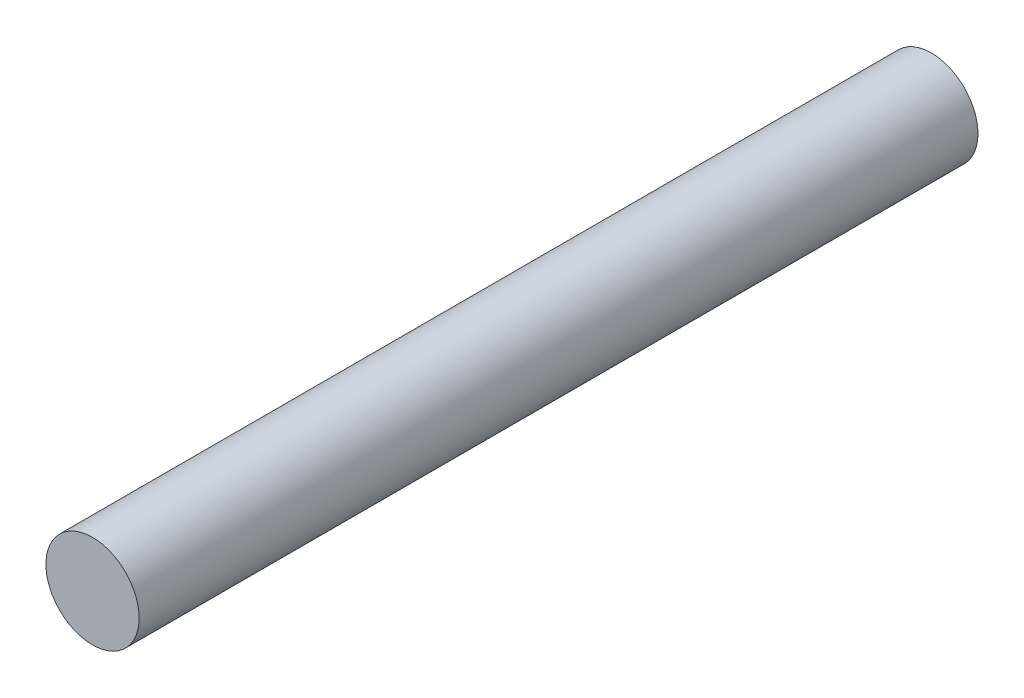
from build123d import *

# Parameters (mm, degrees)
SKETCH1_R           = 2.5
BOSS_EXTRUDE1_DEPTH = 45


with BuildPart() as part:
    # Sketch1 → Boss-Extrude1 (new body)
    with BuildSketch(Plane.XY):
        Circle(SKETCH1_R)
    extrude(amount=BOSS_EXTRUDE1_DEPTH)


solid = part.part
